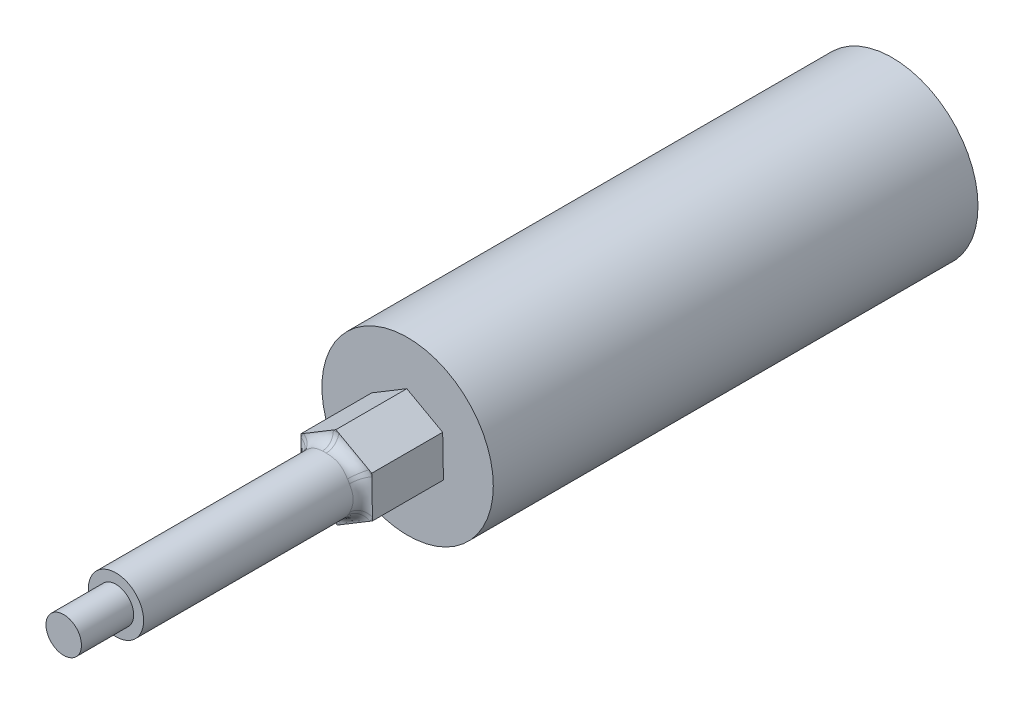
from build123d import *

# Parameters (mm, degrees)
SKETCH2_R           = 7.25
BOSS_EXTRUDE1_DEPTH = 41
BOSS_EXTRUDE2_DEPTH = 6
SKETCH4_R           = 2.34
BOSS_EXTRUDE3_DEPTH = 18.67
FILLET1_R           = 1
SKETCH5_R           = 1.5
BOSS_EXTRUDE4_DEPTH = 4.42


with BuildPart() as part:
    # Sketch2 → Boss-Extrude1 (new body)
    with BuildSketch(Plane.XY):
        Circle(SKETCH2_R)
    extrude(amount=BOSS_EXTRUDE1_DEPTH)

    # Sketch3 → Boss-Extrude2 (add)
    with BuildSketch(Plane.XY.offset(41)):
        Polygon((3.031985372, -1.675429707), (2.966957375, 1.788061503), (-0.065027998, 3.46349121), (-3.031985372, 1.675429707), (-2.966957375, -1.788061503), (0.065027998, -3.46349121), align=None)
    extrude(amount=BOSS_EXTRUDE2_DEPTH)

    # Sketch4 → Boss-Extrude3 (add)
    with BuildSketch(Plane.XY.offset(47)):
        Circle(SKETCH4_R)
    extrude(amount=BOSS_EXTRUDE3_DEPTH)

    # Fillet1
    fillet1_edges = [part.edges().sort_by_distance(p)[0] for p in [
        (-2.34, 0, 47),
    ]]
    fillet(fillet1_edges, radius=FILLET1_R)

    # Sketch5 → Boss-Extrude4 (add)
    with BuildSketch(Plane.XY.offset(65.67)):
        Circle(SKETCH5_R)
    extrude(amount=BOSS_EXTRUDE4_DEPTH)


solid = part.part
